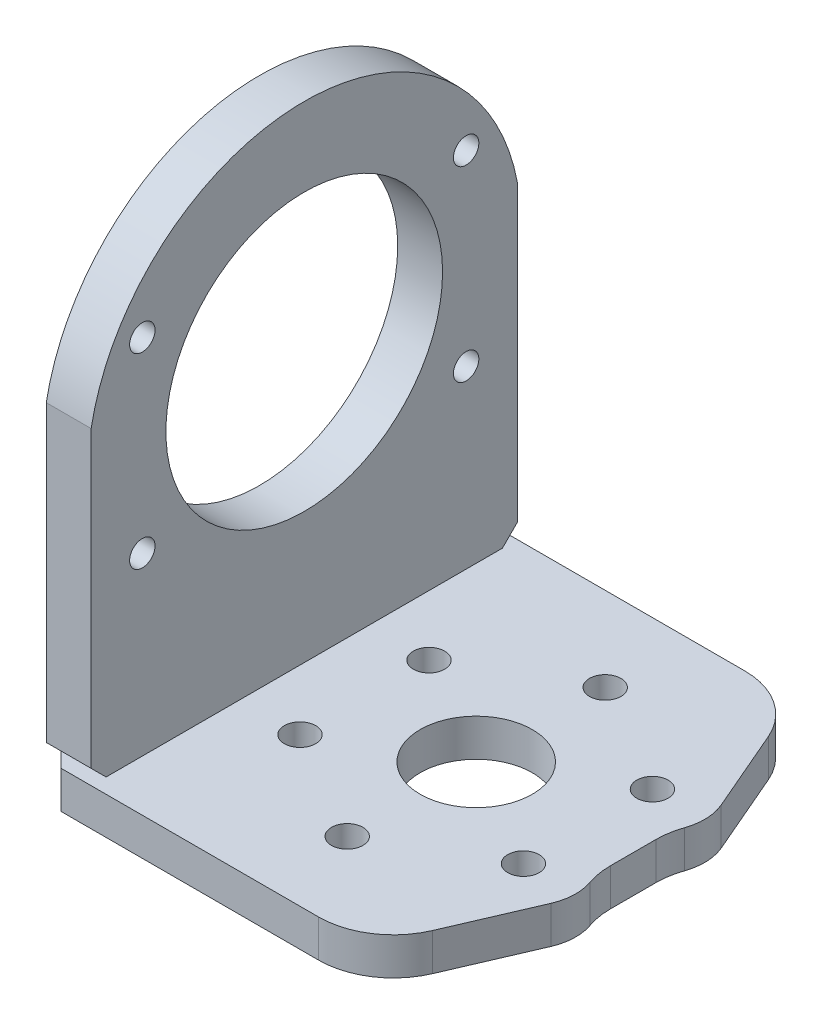
from build123d import *

# Parameters (mm, degrees)
SKETCH_1_W                    = 58
SKETCH_1_H                    = 57
EXTRUDE_1_DEPTH               = 5
SKETCH_5_R                    = 1
SKETCH_5_R_2                  = 2.1
CUT_EXTRUDE_2_DEPTH           = 6
HOLE_WIZARD_M3_1_D            = 3.4
HOLE_WIZARD_M3_1_DEPTH        = 5.5
HOLE_WIZARD_M3_1_CSINK_D      = 6.6
HOLE_WIZARD_M3_1_CSINK_ANGLE  = 90
HOLE_WIZARD_M3_1_TIP          = 1.021463052
CHAMFER_1_SIZE                = 2
SKETCH_9_W                    = 6
SKETCH_9_H                    = 57
EXTRUDE_3_DEPTH               = 68
SKETCH_10_R                   = 18.5
CUT_EXTRUDE_3_DEPTH           = 7
CHAMFER_2_SIZE                = 2
SKETCH_11_R                   = 7.5
CUT_EXTRUDE_4_DEPTH           = 6
SKETCH_12_R                   = 1
CUT_EXTRUDE_5_DEPTH           = 59
HOLE_WIZARD_M3_1_2_AT_2_COUNT = 2
HOLE_WIZARD_M3_1_2_AT_2_PITCH = 43.301270189
HOLE_WIZARD_M3_1_2_AT_3_COUNT = 2
HOLE_WIZARD_M3_1_2_AT_3_PITCH = 50
HOLE_WIZARD_M3_1_2_AT_4_COUNT = 2
HOLE_WIZARD_M3_1_2_AT_4_PITCH = 25
CUT_EXTRUDE_6_DEPTH           = 10
SKETCH_15_R                   = 0.05
CUT_EXTRUDE_7_DEPTH           = 0.1
SKETCH_16_R                   = 0.05
CUT_EXTRUDE_8_DEPTH           = 0.1
CUT_EXTRUDE_9_DEPTH           = 10
FILLET_1_R                    = 10
SKETCH_18_R                   = 1.65
CUT_EXTRUDE_10_DEPTH          = 5
HOLE_WIZARD_M3_1_3_AT_2_COUNT = 2
HOLE_WIZARD_M3_1_3_AT_2_PITCH = 21
HOLE_WIZARD_M3_1_3_AT_3_COUNT = 2
HOLE_WIZARD_M3_1_3_AT_3_PITCH = 42


with BuildPart() as part:
    # 草图1 → 凸台-拉伸1 (new body)
    with BuildSketch(Plane(origin=(0, 0, 0), x_dir=(1, 0, 0), z_dir=(0, 1, 0))):
        Rectangle(SKETCH_1_W, SKETCH_1_H)
    extrude(amount=EXTRUDE_1_DEPTH)

    # 草图5 → 切除-拉伸2 (cut, through all)
    with BuildSketch(Plane(origin=(0, 5, 0), x_dir=(1, 0, 0), z_dir=(0, 1, 0))):
        with Locations((-26, 21)):
            Circle(SKETCH_5_R)
        with Locations((-26, -21)):
            Circle(SKETCH_5_R)
        with Locations((0, 17.25)):
            Circle(SKETCH_5_R_2)
        with Locations((14.938938215, 8.625)):
            Circle(SKETCH_5_R_2)
        with Locations((14.938938215, -8.625)):
            Circle(SKETCH_5_R_2)
        with Locations((0, -17.25)):
            Circle(SKETCH_5_R_2)
        with Locations((-14.938938215, -8.625)):
            Circle(SKETCH_5_R_2)
        with Locations((-14.938938215, 8.625)):
            Circle(SKETCH_5_R_2)
    extrude(amount=-CUT_EXTRUDE_2_DEPTH, mode=Mode.SUBTRACT)

    # Hole Wizard M3 _1
    with Locations(Plane(origin=(-26, 0, 21), x_dir=(0, 0, -1), z_dir=(0, -1, 0))):
        with Locations((0, 0), (42, 0)):
            CounterSinkHole(HOLE_WIZARD_M3_1_D / 2, HOLE_WIZARD_M3_1_CSINK_D / 2, depth=HOLE_WIZARD_M3_1_DEPTH, counter_sink_angle=HOLE_WIZARD_M3_1_CSINK_ANGLE)
            with Locations((0, 0, -(HOLE_WIZARD_M3_1_DEPTH + HOLE_WIZARD_M3_1_TIP / 2))):  # 118° drill point
                Cone(0, HOLE_WIZARD_M3_1_D / 2, HOLE_WIZARD_M3_1_TIP, mode=Mode.SUBTRACT)

    # 倒角1
    chamfer_1_edges = [part.edges().sort_by_distance(p)[0] for p in [
        (29, 2.5, 28.5),
        (-29, 2.5, 28.5),
        (-29, 2.5, -28.5),
        (29, 2.5, -28.5),
    ]]
    chamfer(chamfer_1_edges, length=CHAMFER_1_SIZE)

    # 草图11 → 切除-拉伸4 (cut, through all)
    with BuildSketch(Plane(origin=(0, 5, 0), x_dir=(1, 0, 0), z_dir=(0, 1, 0))):
        Circle(SKETCH_11_R)
    extrude(amount=-CUT_EXTRUDE_4_DEPTH, mode=Mode.SUBTRACT)

    # 草图15 → 切除-拉伸7 (cut)
    with BuildSketch(Plane(origin=(0, 0, -28.5), x_dir=(-1, 0, 0), z_dir=(0, 0, -1))):
        with Locations((0, 2.5)):
            Circle(SKETCH_15_R)
    extrude(amount=-CUT_EXTRUDE_7_DEPTH, mode=Mode.SUBTRACT)

    # 草图16 → 切除-拉伸8 (cut)
    with BuildSketch(Plane.ZY.offset(29)):
        with Locations((0, 2.5)):
            Circle(SKETCH_16_R)
    extrude(amount=-CUT_EXTRUDE_8_DEPTH, mode=Mode.SUBTRACT)

    # 草图17 → 切除-拉伸9 (cut)
    with BuildSketch(Plane(origin=(0, 5, 0), x_dir=(1, 0, 0), z_dir=(0, 1, 0))):
        with BuildLine():
            Line((14, 28.5), (21.36792945, 11.39412833))
            ThreePointArc((21.36792945, 11.39412833), (21.926921226, 8.215007993), (21, 5.12306767))
            Line((21, 5.12306767), (21, -5.12306767))
            ThreePointArc((21, -5.12306767), (21.926921226, -8.215007993), (21.36792945, -11.39412833))
            Line((21.36792945, -11.39412833), (14, -28.5))
            Line((14, -28.5), (27, -28.5))
            Line((27, -28.5), (29, -26.5))
            Line((29, -26.5), (29, 26.5))
            Line((29, 26.5), (27, 28.5))
            Line((27, 28.5), (14, 28.5))
        make_face()
    extrude(amount=-CUT_EXTRUDE_9_DEPTH, mode=Mode.SUBTRACT)

    # 圆角1
    fillet_1_edges = [part.edges().sort_by_distance(p)[0] for p in [
        (14, 2.5, 28.5),
        (21, 2.5, 5.12306767),
        (21, 2.5, -5.12306767),
        (14, 2.5, -28.5),
    ]]
    fillet(fillet_1_edges, radius=FILLET_1_R)

    # 草图18 → 切除-拉伸10 (cut)
    with BuildSketch(Plane.XZ):
        with Locations((-26, 0)):
            Circle(SKETCH_18_R)
    extrude(amount=-CUT_EXTRUDE_10_DEPTH, mode=Mode.SUBTRACT)


with BuildPart() as body_2:
    # 草图9 → 凸台-拉伸3 (new body)
    with BuildSketch(Plane(origin=(0, 5, 0), x_dir=(1, 0, 0), z_dir=(0, 1, 0))):
        with Locations((-26, 0)):
            Rectangle(SKETCH_9_W, SKETCH_9_H)
    extrude(amount=EXTRUDE_3_DEPTH)

    # 草图10 → 切除-拉伸3 (cut, through all)
    with BuildSketch(Plane(origin=(-23, 0, 0), x_dir=(0, 0, -1), z_dir=(1, 0, 0))):
        with Locations((0, 41)):
            Circle(SKETCH_10_R)
    extrude(amount=-CUT_EXTRUDE_3_DEPTH, mode=Mode.SUBTRACT)

    # 倒角2
    chamfer_2_edges = [body_2.edges().sort_by_distance(p)[0] for p in [
        (-26, 5, -28.5),
        (-26, 5, 28.5),
    ]]
    chamfer(chamfer_2_edges, length=CHAMFER_2_SIZE)

    # 草图12 → 切除-拉伸5 (cut, through all)
    with BuildSketch(Plane.ZY.offset(29)):
        with Locations((21.650635095, 53.5)):
            Circle(SKETCH_12_R)
        with Locations((21.650635095, 28.5)):
            Circle(SKETCH_12_R)
        with Locations((-21.650635095, 28.5)):
            Circle(SKETCH_12_R)
        with Locations((-21.650635095, 53.5)):
            Circle(SKETCH_12_R)
    extrude(amount=-CUT_EXTRUDE_5_DEPTH, mode=Mode.SUBTRACT)

    # 草图13 → Hole Wizard M3 _1 2 (revolve, cut)
    with BuildSketch(Plane(origin=(-29, 53.5, -21.650635095), x_dir=(0, 0, 1), z_dir=(0, 1, 0))):
        Polygon((0, 0), (0, 58), (1.7, 58), (1.7, 3.4), (3, 3.4), (3, 0), align=None)
    hole_wizard_m3_1_2 = revolve(axis=Axis((-35.35, 53.5, -21.650635095), (1, 0, 0)), mode=Mode.SUBTRACT)

    # Hole Wizard M3 _1 2 at 2: Hole Wizard M3 _1 2 ×2
    with Locations(*[(0, 0, i * HOLE_WIZARD_M3_1_2_AT_2_PITCH) for i in range(1, HOLE_WIZARD_M3_1_2_AT_2_COUNT)]):
        add(hole_wizard_m3_1_2, mode=Mode.SUBTRACT)

    # Hole Wizard M3 _1 2 at 3: Hole Wizard M3 _1 2 ×2
    with Locations(*[Vector(0, -0.5, 0.866025404) * (i * HOLE_WIZARD_M3_1_2_AT_3_PITCH) for i in range(1, HOLE_WIZARD_M3_1_2_AT_3_COUNT)]):
        add(hole_wizard_m3_1_2, mode=Mode.SUBTRACT)

    # Hole Wizard M3 _1 2 at 4: Hole Wizard M3 _1 2 ×2
    with Locations(*[(0, -i * HOLE_WIZARD_M3_1_2_AT_4_PITCH, 0) for i in range(1, HOLE_WIZARD_M3_1_2_AT_4_COUNT)]):
        add(hole_wizard_m3_1_2, mode=Mode.SUBTRACT)

    # 草图14 → 切除-拉伸6 (cut)
    with BuildSketch(Plane.ZY.offset(29)):
        with BuildLine():
            Line((28.5, 46.361902647), (28.5, 73))
            Line((28.5, 73), (-28.5, 73))
            Line((-28.5, 73), (-28.5, 46.361902647))
            ThreePointArc((-28.5, 46.361902647), (0, 70), (28.5, 46.361902647))
        make_face()
    extrude(amount=-CUT_EXTRUDE_6_DEPTH, mode=Mode.SUBTRACT)

    # 草图21 → Hole Wizard M3 _1 3 (revolve, cut)
    with BuildSketch(Plane(origin=(-26, 5, -21), x_dir=(0, 0, -1), z_dir=(1, 0, 0))):
        Polygon((0, 0), (0, 6.751075774), (1.25, 6), (1.25, 0), align=None)
    hole_wizard_m3_1_3 = revolve(axis=Axis((-26, -1.35, -21), (0, 1, 0)), mode=Mode.SUBTRACT)

    # Hole Wizard M3 _1 3 at 2: Hole Wizard M3 _1 3 ×2
    with Locations(*[(0, 0, i * HOLE_WIZARD_M3_1_3_AT_2_PITCH) for i in range(1, HOLE_WIZARD_M3_1_3_AT_2_COUNT)]):
        add(hole_wizard_m3_1_3, mode=Mode.SUBTRACT)

    # Hole Wizard M3 _1 3 at 3: Hole Wizard M3 _1 3 ×2
    with Locations(*[(0, 0, i * HOLE_WIZARD_M3_1_3_AT_3_PITCH) for i in range(1, HOLE_WIZARD_M3_1_3_AT_3_COUNT)]):
        add(hole_wizard_m3_1_3, mode=Mode.SUBTRACT)


solid = Compound([part.part, body_2.part])
